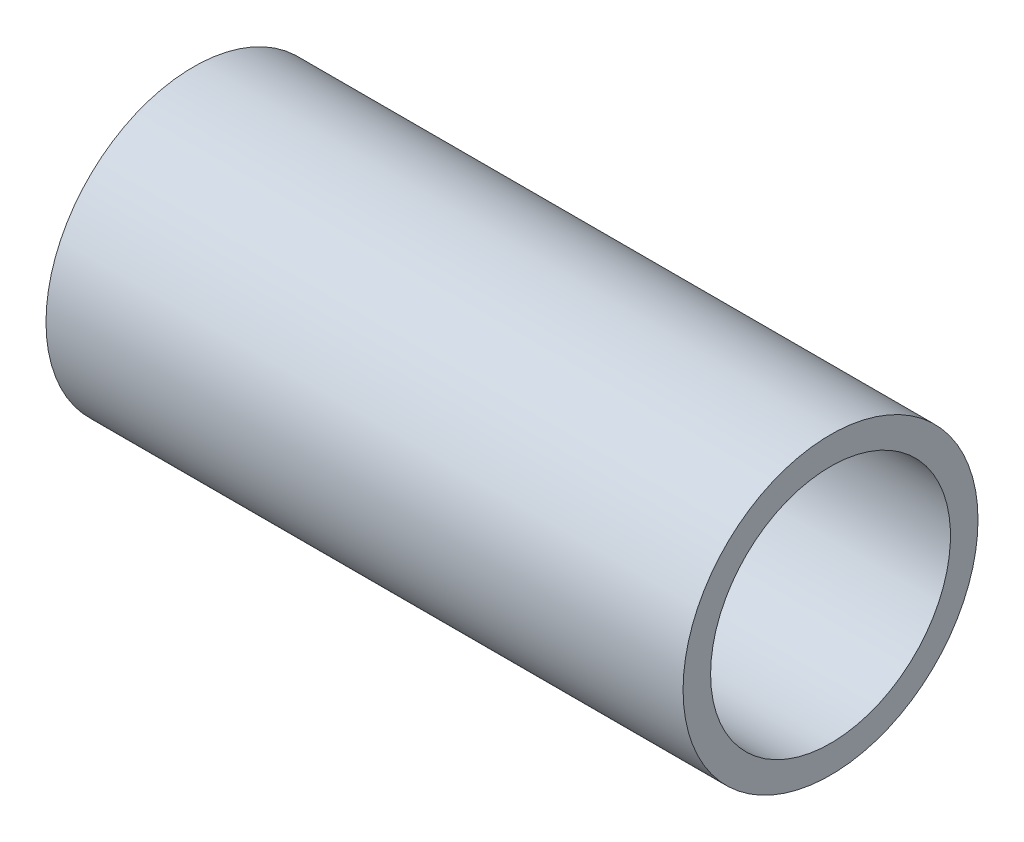
from build123d import *

# Parameters (mm, degrees)
SKETCH1_W = 162
SKETCH1_H = 7


with BuildPart() as part:
    # Sketch1 → Revolve1 (revolve)
    with BuildSketch(Plane.XY):
        with Locations((0, 34)):
            Rectangle(SKETCH1_W, SKETCH1_H)
    revolve(axis=Axis((0, 0, 0), (1, 0, 0)))


solid = part.part
